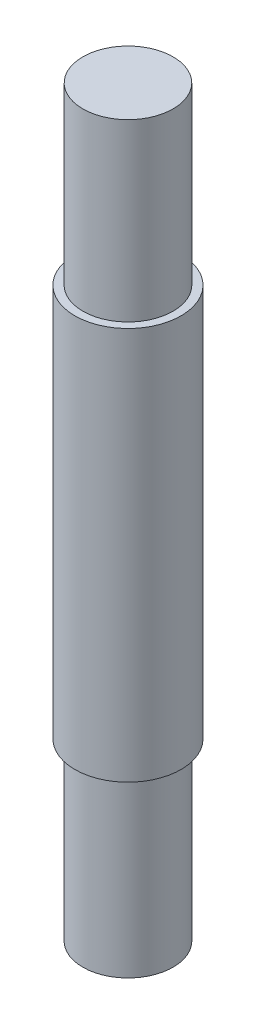
from build123d import *

# Parameters (mm, degrees)
BOSS_EXTRUDE1_DEPTH      = 70
BOSS_EXTRUDE1_DEPTH_BACK = 70
SKETCH1_R                = 8.5
BOSS_EXTRUDE2_DEPTH      = 37
BOSS_EXTRUDE2_DEPTH_BACK = 37
SKETCH2_R                = 10


with BuildPart() as part:
    # Sketch1 → Boss-Extrude1 (new, two sides: drawn at the far end of the back side and taken through both)
    with BuildSketch(Plane(origin=(0, 0, 0), x_dir=(1, 0, 0), z_dir=(0, 1, 0)).offset(-BOSS_EXTRUDE1_DEPTH_BACK)):
        Circle(SKETCH1_R)
    extrude(amount=BOSS_EXTRUDE1_DEPTH + BOSS_EXTRUDE1_DEPTH_BACK)

    # Sketch2 → Boss-Extrude2 (add, two sides: drawn at the far end of the back side and taken through both)
    with BuildSketch(Plane(origin=(0, 0, 0), x_dir=(1, 0, 0), z_dir=(0, 1, 0)).offset(-BOSS_EXTRUDE2_DEPTH_BACK)):
        Circle(SKETCH2_R)
    extrude(amount=BOSS_EXTRUDE2_DEPTH + BOSS_EXTRUDE2_DEPTH_BACK)


solid = part.part
